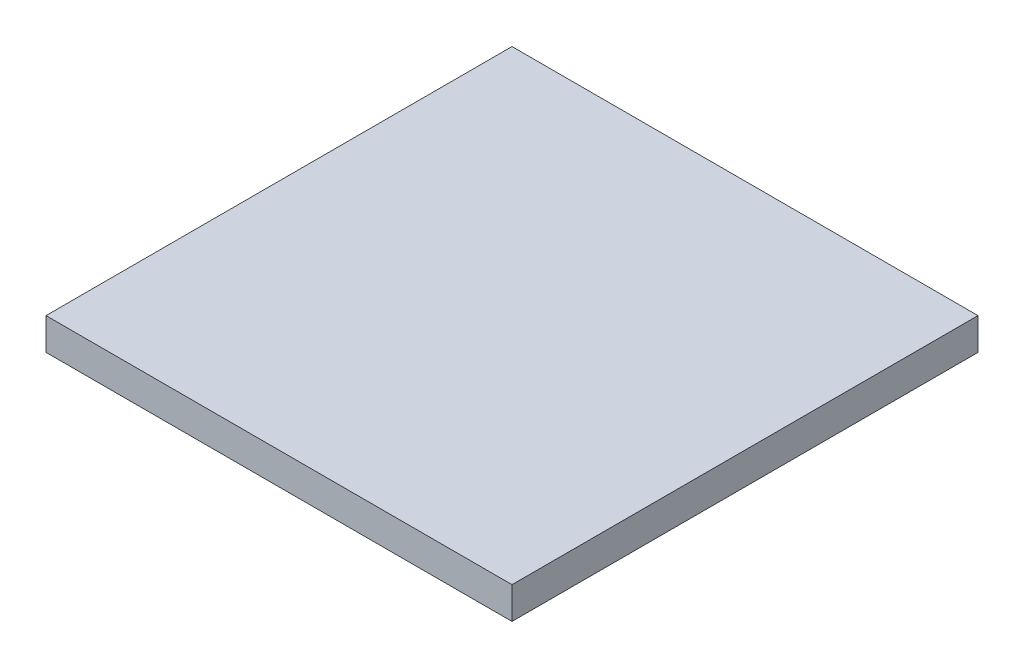
from build123d import *

# Parameters (mm, degrees)
SKETCH1_W           = 50
SKETCH1_H           = 50
BOSS_EXTRUDE1_DEPTH = 3.42


with BuildPart() as part:
    # Sketch1 → Boss-Extrude1 (new body)
    with BuildSketch(Plane(origin=(0, 0, 0), x_dir=(1, 0, 0), z_dir=(0, 1, 0))):
        with Locations((0.547445255, -6.295620438)):
            Rectangle(SKETCH1_W, SKETCH1_H)
    extrude(amount=BOSS_EXTRUDE1_DEPTH)


solid = part.part
